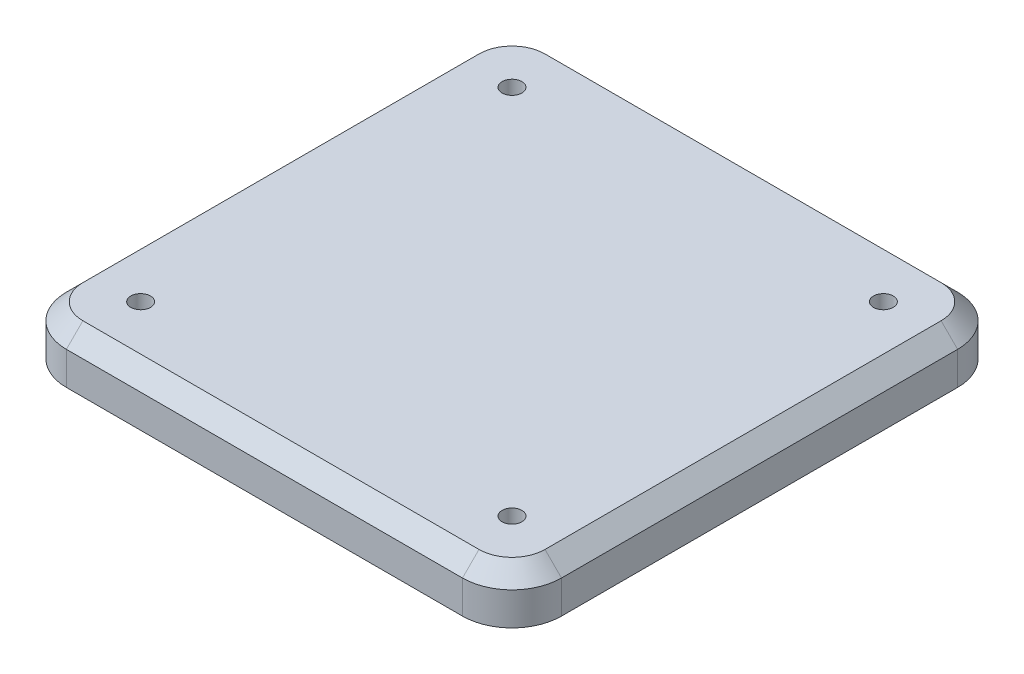
from build123d import *

# Parameters (mm, degrees)
CROQUIS1_W              = 300
CROQUIS1_H              = 300
SALIENTE_EXTRUIR1_DEPTH = 30
REDONDEO1_R             = 30
CHAFL_N1_SIZE           = 10
CROQUIS3_R              = 6
CORTAR_EXTRUIR2_DEPTH   = 10
CROQUIS11_R             = 6
CORTAR_EXTRUIR5_DEPTH   = 10


with BuildPart() as part:
    # Croquis1 → Saliente-Extruir1 (new body)
    with BuildSketch(Plane(origin=(0, 0, 0), x_dir=(1, 0, 0), z_dir=(0, 1, 0))):
        Rectangle(CROQUIS1_W, CROQUIS1_H)
    extrude(amount=SALIENTE_EXTRUIR1_DEPTH)

    # Redondeo1
    redondeo1_edges = [part.edges().sort_by_distance(p)[0] for p in [
        (150, 15, 150),
        (-150, 15, 150),
        (-150, 15, -150),
        (150, 15, -150),
    ]]
    fillet(redondeo1_edges, radius=REDONDEO1_R)

    # Chaflán1
    chafl_n1_edges = [part.edges().sort_by_distance(p)[0] for p in [
        (-150, 30, 0),
        (0, 30, -150),
        (150, 30, 0),
        (0, 30, 150),
        (-141.213203436, 30, 141.213203436),
        (141.213203436, 30, 141.213203436),
        (141.213203436, 30, -141.213203436),
        (-141.213203436, 30, -141.213203436),
    ]]
    chamfer(chafl_n1_edges, length=CHAFL_N1_SIZE)

    # Croquis3 → Cortar-Extruir2 (cut)
    with BuildSketch(Plane.XZ):
        with Locations((125, -125)):
            Circle(CROQUIS3_R)
        with Locations((125, 125)):
            Circle(CROQUIS3_R)
        with Locations((-125, 125)):
            Circle(CROQUIS3_R)
        with Locations((-125, -125)):
            Circle(CROQUIS3_R)
    extrude(amount=-CORTAR_EXTRUIR2_DEPTH, mode=Mode.SUBTRACT)

    # Croquis11 → Cortar-Extruir5 (cut)
    with BuildSketch(Plane(origin=(0, 30, 0), x_dir=(1, 0, 0), z_dir=(0, 1, 0))):
        with Locations((112.5, -112.5)):
            Circle(CROQUIS11_R)
        with Locations((112.5, 112.5)):
            Circle(CROQUIS11_R)
        with Locations((-112.5, 112.5)):
            Circle(CROQUIS11_R)
        with Locations((-112.5, -112.5)):
            Circle(CROQUIS11_R)
    extrude(amount=-CORTAR_EXTRUIR5_DEPTH, mode=Mode.SUBTRACT)


solid = part.part
